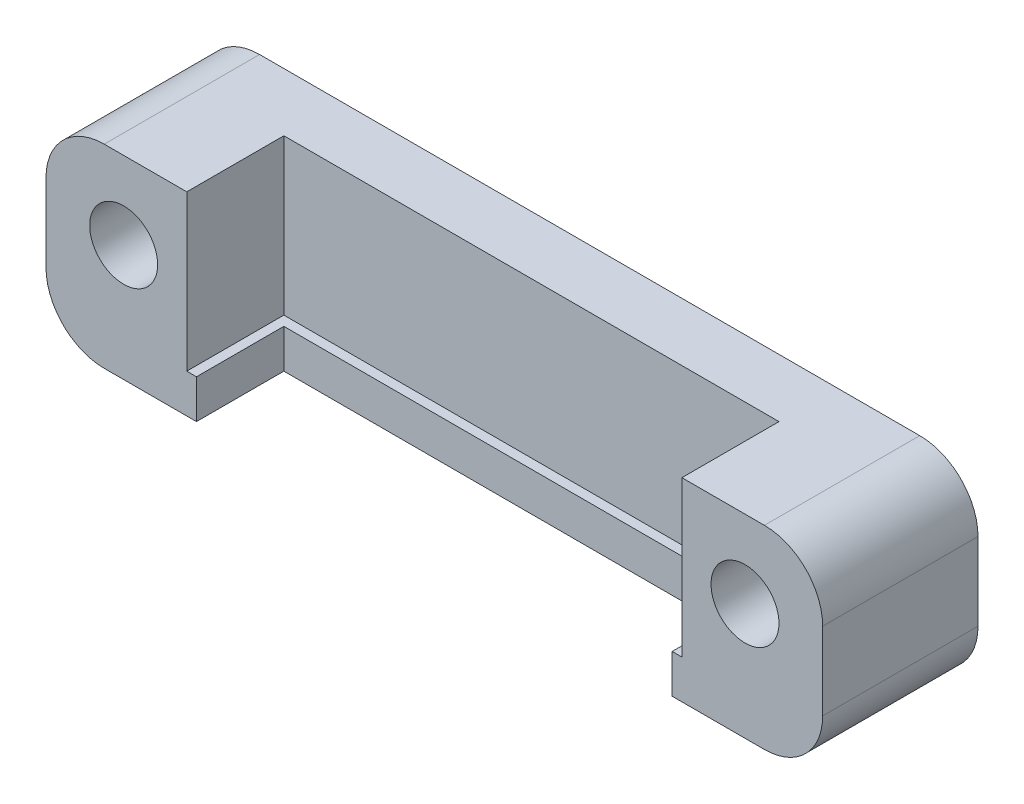
from build123d import *

# Parameters (mm, degrees)
SKETCH1_R           = 1.75
BOSS_EXTRUDE1_DEPTH = 8
SKETCH2_W           = 25.5
SKETCH2_H           = 8
CUT_EXTRUDE1_DEPTH  = 5
SKETCH3_W           = 24.5
SKETCH3_H           = 4.5
CUT_EXTRUDE2_DEPTH  = 3


with BuildPart() as part:
    # Sketch1 → Boss-Extrude1 (new body)
    with BuildSketch(Plane.XY):
        with BuildLine():
            Line((-17, 10), (17, 10))
            ThreePointArc((17, 10), (19.121320344, 9.121320344), (20, 7))
            Line((20, 7), (20, 3))
            ThreePointArc((20, 3), (19.121320344, 0.878679656), (17, 0))
            Line((17, 0), (-17, 0))
            ThreePointArc((-17, 0), (-19.121320344, 0.878679656), (-20, 3))
            Line((-20, 3), (-20, 7))
            ThreePointArc((-20, 7), (-19.121320344, 9.121320344), (-17, 10))
        make_face()
        with Locations((-16, 6)):
            Circle(SKETCH1_R, mode=Mode.SUBTRACT)
        with Locations((16, 6)):
            Circle(SKETCH1_R, mode=Mode.SUBTRACT)
    extrude(amount=BOSS_EXTRUDE1_DEPTH)

    # Sketch2 → Cut-Extrude1 (cut)
    with BuildSketch(Plane.XY.offset(8)):
        with Locations((0, 6)):
            Rectangle(SKETCH2_W, SKETCH2_H)
    extrude(amount=-CUT_EXTRUDE1_DEPTH, mode=Mode.SUBTRACT)

    # Sketch3 → Cut-Extrude2 (cut, through all)
    with BuildSketch(Plane(origin=(0, 2, 0), x_dir=(1, 0, 0), z_dir=(0, 1, 0))):
        with Locations((0, -5.75)):
            Rectangle(SKETCH3_W, SKETCH3_H)
    extrude(amount=-CUT_EXTRUDE2_DEPTH, mode=Mode.SUBTRACT)


solid = part.part
